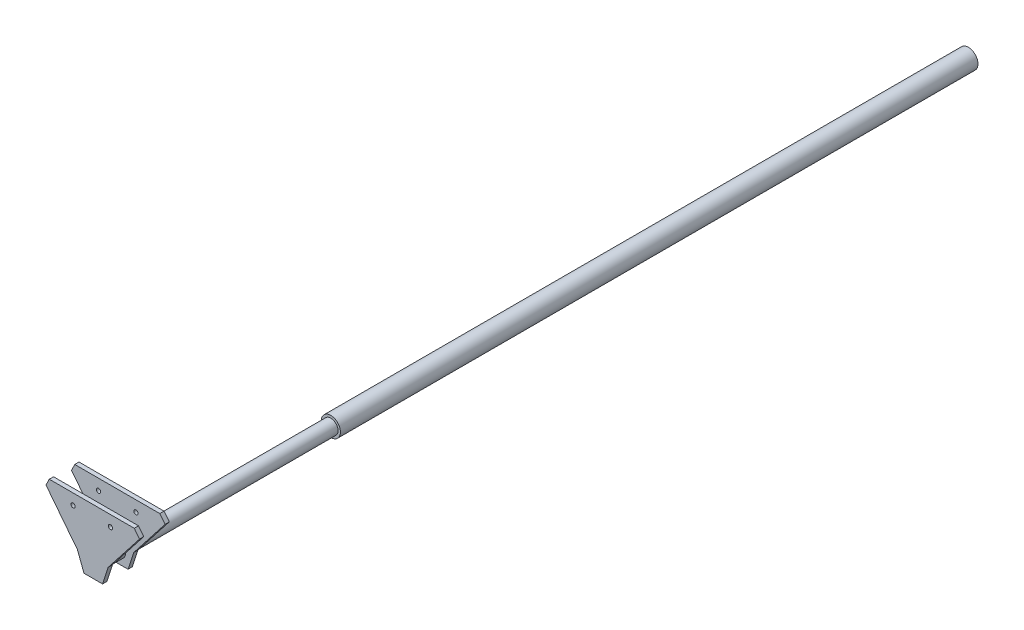
from build123d import *

# Parameters (mm, degrees)
BOSS_EXTRUDE1_START = -380
SKETCH1_R           = 11.3
BOSS_EXTRUDE1_DEPTH = 750
SKETCH2_R           = 8.5
BOSS_EXTRUDE2_DEPTH = 280
BOSS_EXTRUDE3_DEPTH = 5
LPATTERN1_COUNT     = 2
LPATTERN1_PITCH     = 30
SKETCH6_R           = 2.5
CUT_EXTRUDE1_DEPTH  = 150


with BuildPart() as part:
    # Sketch1 → Boss-Extrude1 (new body)
    with BuildSketch(Plane.XY.offset(BOSS_EXTRUDE1_START)):
        Circle(SKETCH1_R)
    extrude(amount=BOSS_EXTRUDE1_DEPTH)

    # Sketch2 → Boss-Extrude2 (add)
    with BuildSketch(Plane.XY.offset(370)):
        Circle(SKETCH2_R)
    extrude(amount=BOSS_EXTRUDE2_DEPTH)

    # Sketch3 → Boss-Extrude3 (add)
    with BuildSketch(Plane.XY.offset(650)):
        Polygon((11.52115326, -14.68790239), (18.072829237, 5.572294102), (55.029019564, 52.840042055), (48.813565956, 60.718856904), (-51.186434044, 60.718856904), (-55.027164938, 52.840905681), (-18.071550308, 5.572707626), (-10.36978253, -14.68790239), (0, -14.68790239), align=None)
    boss_extrude3 = extrude(amount=-BOSS_EXTRUDE3_DEPTH)

    # LPattern1: Boss-Extrude3 ×2
    with Locations(*[(0, 0, -i * LPATTERN1_PITCH) for i in range(1, LPATTERN1_COUNT)]):
        add(boss_extrude3)

    # Sketch6 → Cut-Extrude1 (cut)
    with BuildSketch(Plane.XY.offset(650)):
        with Locations((-23.186517394, 47.937289654)):
            Circle(SKETCH6_R)
        with Locations((20.813649306, 47.937289654)):
            Circle(SKETCH6_R)
    extrude(amount=-CUT_EXTRUDE1_DEPTH, mode=Mode.SUBTRACT)


solid = part.part
